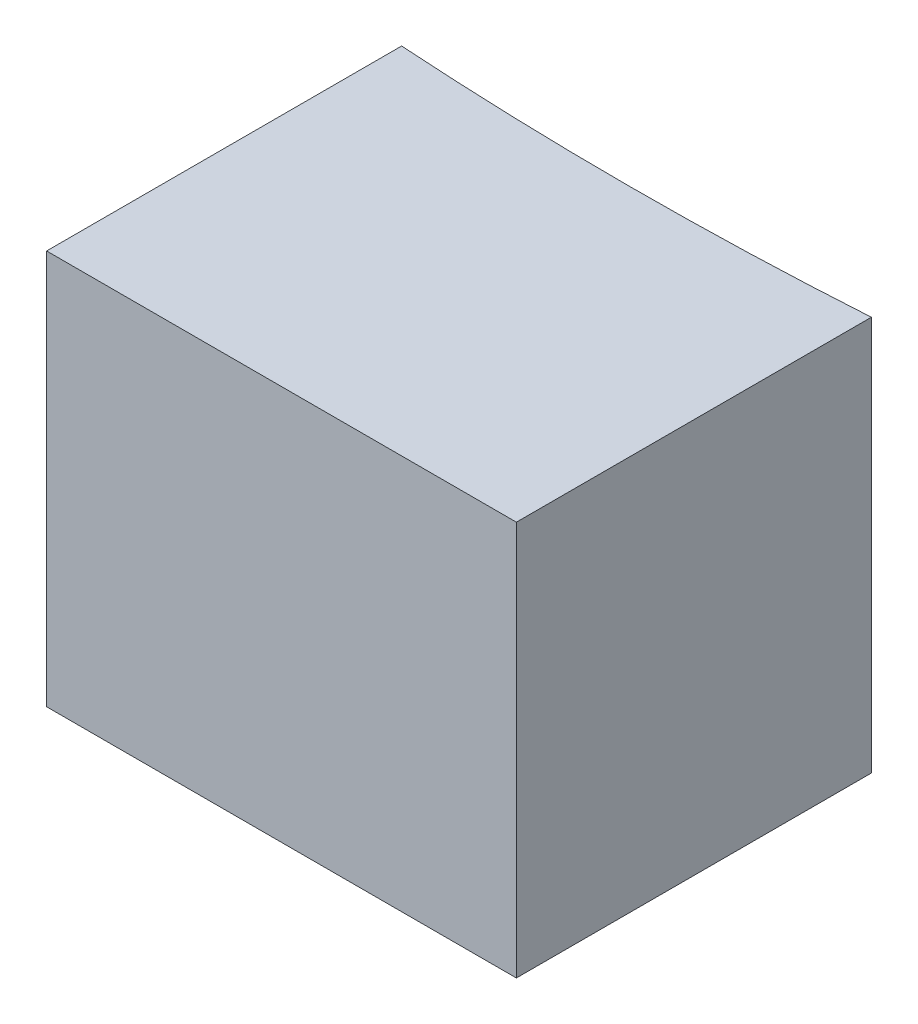
from build123d import *

# Parameters (mm, degrees)
BOSS_EXTRUDE1_DEPTH = 25.4


with BuildPart() as part:
    # Sketch1 → Boss-Extrude1 (new body)
    with BuildSketch(Plane(origin=(0, 0, 0), x_dir=(1, 0, 0), z_dir=(0, 1, 0))):
        with BuildLine():
            Line((15.113, -233.063512889), (15.113, -255.905))
            Line((15.113, -255.905), (-15.113, -255.905))
            Line((-15.113, -255.905), (-15.113, -233.063512889))
            ThreePointArc((-15.113, -233.063512889), (0, -233.553), (15.113, -233.063512889))
        make_face()
    extrude(amount=BOSS_EXTRUDE1_DEPTH)


solid = part.part
